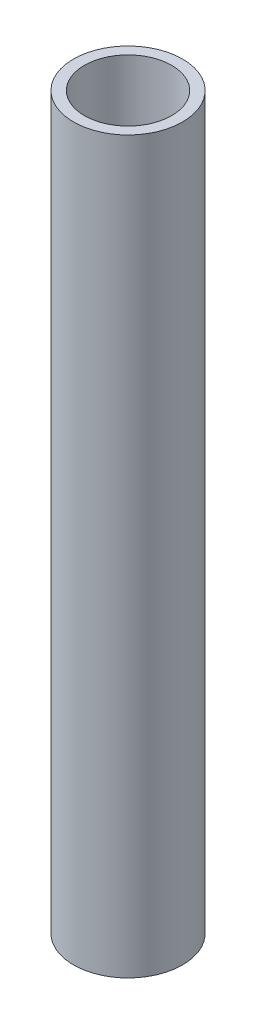
from build123d import *


with BuildPart() as part:
    # Эскиз2 → Повернуть1 (revolve)
    with BuildSketch(Plane(origin=(0, 0, 0), x_dir=(0, 0, -1), z_dir=(1, 0, 0))):
        Polygon((5, 0), (15, 0), (15, 200.817203122), (12, 200.817203122), (12, 10), (5, 10), align=None)
    revolve(axis=Axis((0, 0, 0), (0, 1, 0)))


solid = part.part
